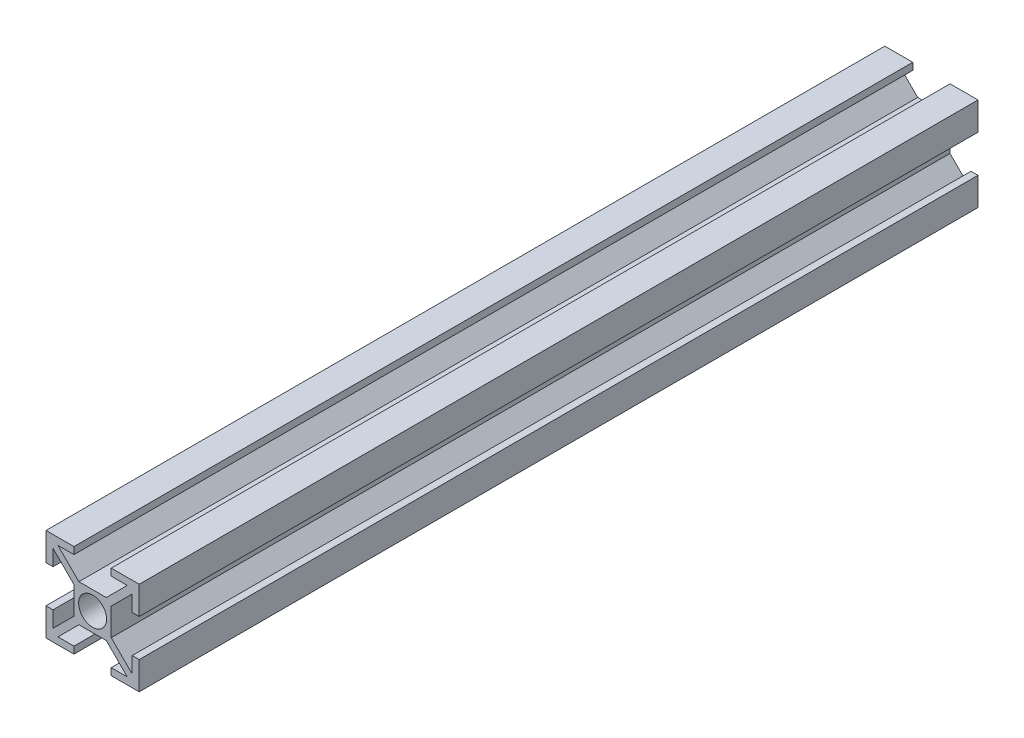
from build123d import *

# Parameters (mm, degrees)
ESBO_O1_R                = 3
RESSALTO_EXTRUS_O1_DEPTH = 180


with BuildPart() as part:
    # Esboço1 → Ressalto-extrusão1 (new body)
    with BuildSketch(Plane.XY):
        Polygon((-2.939339828, 4), (2.939339828, 4), (7.439339828, 8.5), (4, 8.5), (4, 10), (10, 10), (10, 4), (8.5, 4), (8.5, 7.439339828), (4, 2.939339828), (4, -2.939339828), (8.5, -7.439339828), (8.5, -4), (10, -4), (10, -10), (4, -10), (4, -8.5), (7.439339828, -8.5), (2.939339828, -4), (-2.939339828, -4), (-7.439339828, -8.5), (-4, -8.5), (-4, -10), (-10, -10), (-10, -4), (-8.5, -4), (-8.5, -7.439339828), (-4, -2.939339828), (-4, 2.939339828), (-8.5, 7.439339828), (-8.5, 4), (-10, 4), (-10, 10), (-4, 10), (-4, 8.5), (-7.439339828, 8.5), align=None)
        Circle(ESBO_O1_R, mode=Mode.SUBTRACT)
    extrude(amount=RESSALTO_EXTRUS_O1_DEPTH)


solid = part.part
